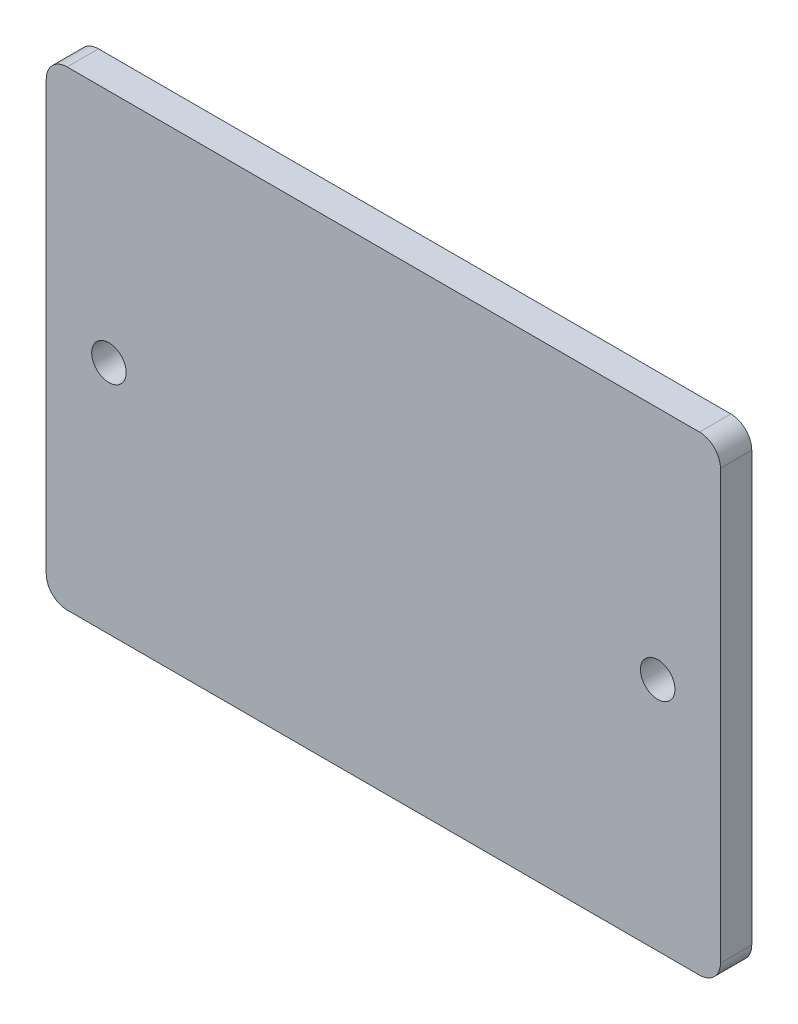
from build123d import *

# Parameters (mm, degrees)
SKETCH_1_W          = 64.5
SKETCH_1_H          = 45
EXTRUDE_1_DEPTH     = 3
SKETCH_6_W          = 12
SKETCH_6_H          = 10
EXTRUDE_4_DEPTH     = 3
FILLET_1_R          = 2
SKETCH_7_R          = 1.65
CUT_EXTRUDE_3_DEPTH = 6
SKETCH_9_W          = 6
SKETCH_9_H          = 14
CUT_EXTRUDE_4_DEPTH = 10
SKETCH_8_R          = 1.65
CUT_EXTRUDE_5_DEPTH = 10


with BuildPart() as part:
    # 草图1 → 凸台-拉伸1 (new body)
    with BuildSketch(Plane.XY):
        Rectangle(SKETCH_1_W, SKETCH_1_H)
    extrude(amount=EXTRUDE_1_DEPTH)

    # 草图6 → 凸台-拉伸4 (add)
    with BuildSketch(Plane.XY.offset(3)):
        with Locations((32.25, 0)):
            Rectangle(SKETCH_6_W, SKETCH_6_H)
        with Locations((-32.25, 0)):
            Rectangle(SKETCH_6_W, SKETCH_6_H)
    extrude(amount=-EXTRUDE_4_DEPTH)

    # 圆角1
    fillet_1_edges = [part.edges().sort_by_distance(p)[0] for p in [
        (38.25, -5, 1.5),
        (32.25, 5, 1.5),
        (32.25, -5, 1.5),
        (38.25, 5, 1.5),
        (-38.25, 5, 1.5),
        (-32.25, 5, 1.5),
        (-38.25, -5, 1.5),
        (-32.25, -5, 1.5),
        (32.25, -22.5, 1.5),
        (-32.25, -22.5, 1.5),
        (-32.25, 22.5, 1.5),
        (32.25, 22.5, 1.5),
    ]]
    fillet(fillet_1_edges, radius=FILLET_1_R)

    # 草图7 → 切除-拉伸3 (cut)
    with BuildSketch(Plane.XY.offset(3)):
        with Locations((-35.25, 0)):
            Circle(SKETCH_7_R)
        with Locations((35.25, 0)):
            Circle(SKETCH_7_R)
    extrude(amount=-CUT_EXTRUDE_3_DEPTH, mode=Mode.SUBTRACT)

    # 草图9 → 切除-拉伸4 (cut)
    with BuildSketch(Plane.XY.offset(3)):
        with Locations((-35.25, 0)):
            Rectangle(SKETCH_9_W, SKETCH_9_H)
        with Locations((35.25, 0)):
            Rectangle(SKETCH_9_W, SKETCH_9_H)
    extrude(amount=-CUT_EXTRUDE_4_DEPTH, mode=Mode.SUBTRACT)

    # 草图8 → 切除-拉伸5 (cut)
    with BuildSketch(Plane.XY.offset(3)):
        with Locations((-26.25, 0)):
            Circle(SKETCH_8_R)
        with Locations((26.25, 0)):
            Circle(SKETCH_8_R)
    extrude(amount=-CUT_EXTRUDE_5_DEPTH, mode=Mode.SUBTRACT)


solid = part.part
